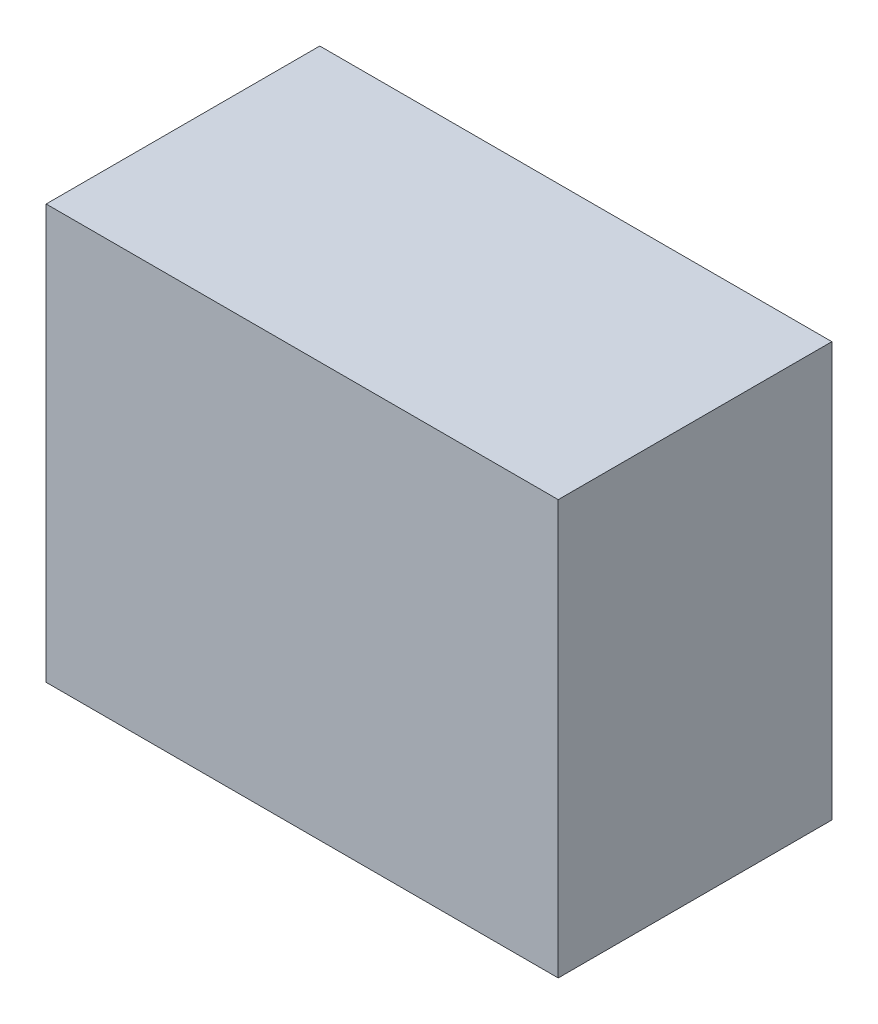
from build123d import *

# Parameters (mm, degrees)
SKETCH1_W           = 46.6
SKETCH1_H           = 37.7
BOSS_EXTRUDE1_DEPTH = 24.9


with BuildPart() as part:
    # Sketch1 → Boss-Extrude1 (new body)
    with BuildSketch(Plane.XY):
        Rectangle(SKETCH1_W, SKETCH1_H)
    extrude(amount=BOSS_EXTRUDE1_DEPTH)


solid = part.part
